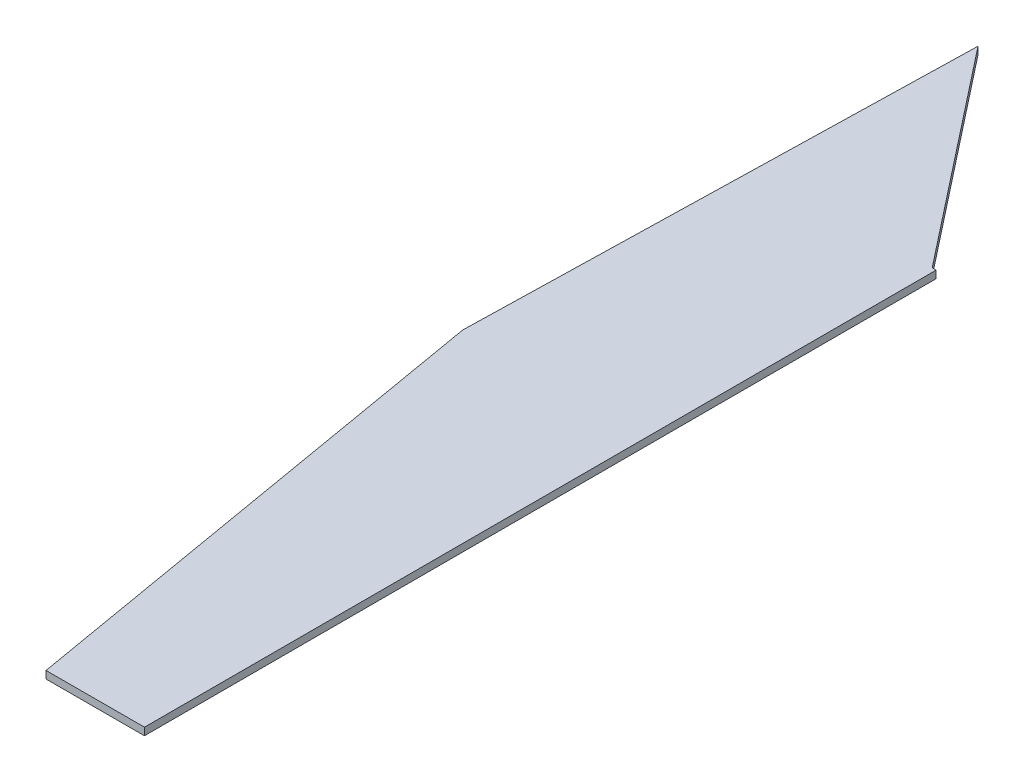
from build123d import *

# Parameters (mm, degrees)
BOSS_EXTRU_1_DEPTH = 2


with BuildPart() as part:
    # Esquisse1 → Boss.-Extru.1 (new body)
    with BuildSketch(Plane(origin=(0, 0, 0), x_dir=(1, 0, 0), z_dir=(0, 1, 0))):
        Polygon((-23.178274329, 134.879998693), (0, 0), (26.362131136, 0.032174861), (26.362131136, 212.216124508), (25.286153349, 212.241517022), (-19.994417521, 269.792172247), align=None)
    extrude(amount=BOSS_EXTRU_1_DEPTH)


solid = part.part
